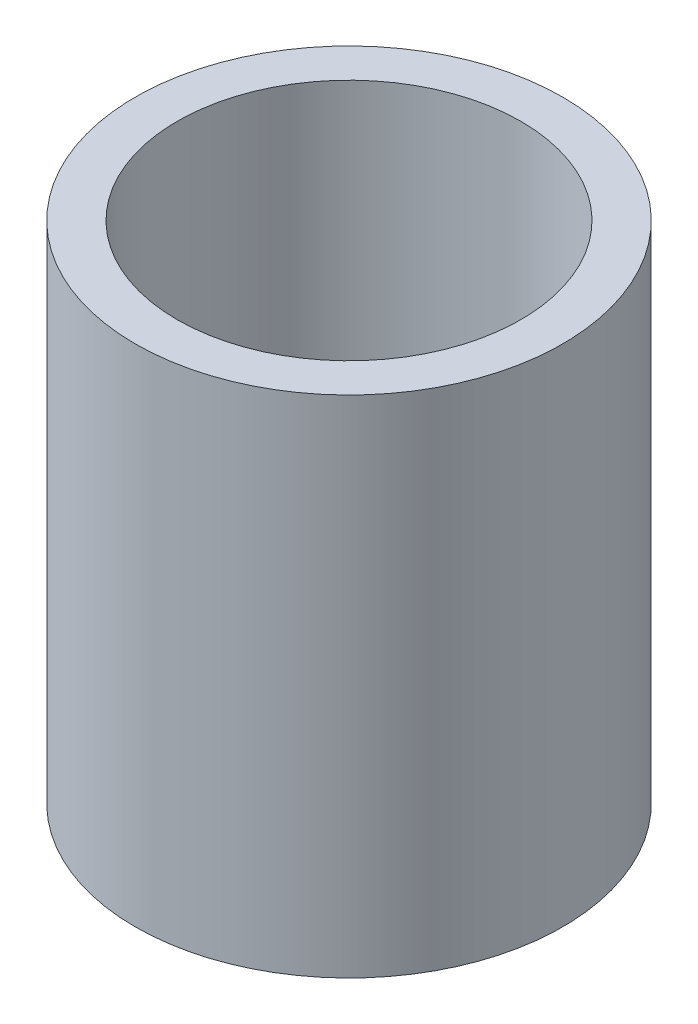
from build123d import *

# Parameters (mm, degrees)
SKETCH1_R           = 6.35
SKETCH1_R_2         = 5.1054
BOSS_EXTRUDE1_DEPTH = 15


with BuildPart() as part:
    # Sketch1 → Boss-Extrude1 (new body)
    with BuildSketch(Plane.XZ.offset(-70.2662795)):
        Circle(SKETCH1_R)
        Circle(SKETCH1_R_2, mode=Mode.SUBTRACT)
    extrude(amount=BOSS_EXTRUDE1_DEPTH)


solid = part.part
